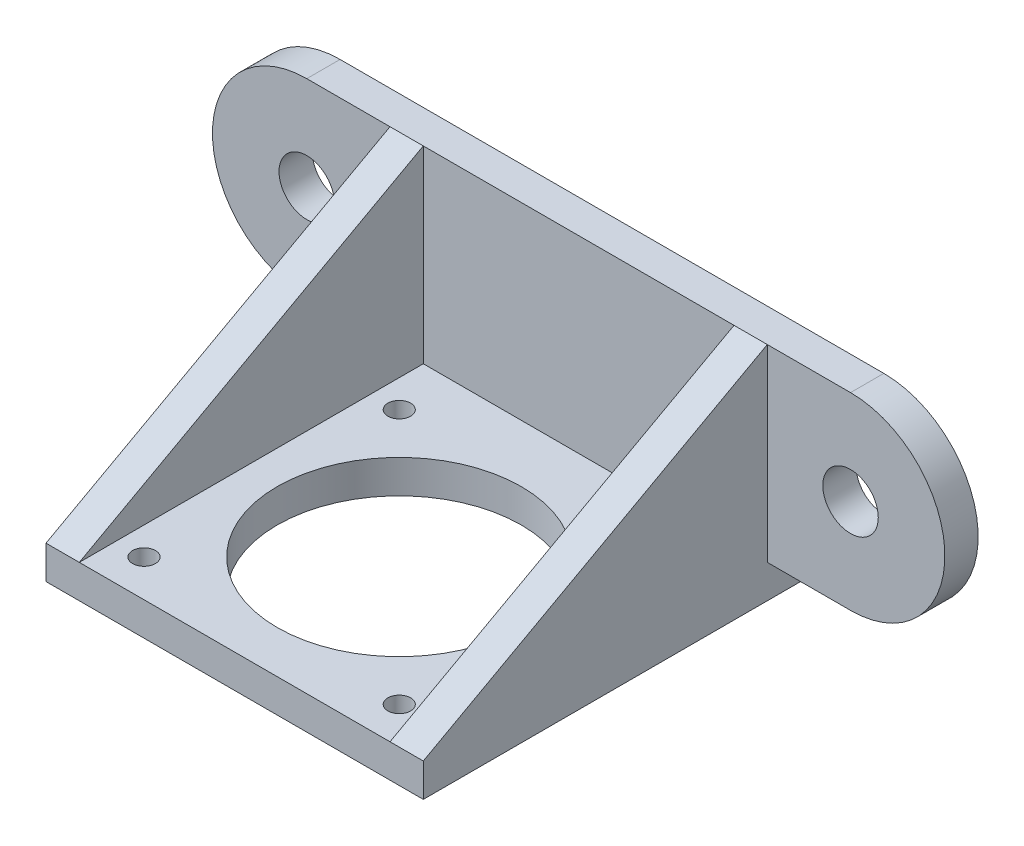
from build123d import *

# Parameters (mm, degrees)
BOSS_EXTRUDE2_DEPTH = 17
RIB2_REACH          = 54.077
SKETCH5_WALL_W      = 141.50907159
SKETCH5_WALL_H      = 3
SKETCH6_R           = 2.5
BOSS_EXTRUDE3_DEPTH = 3
CUT_EXTRUDE1_DEPTH  = 3


with BuildPart() as part:
    # Sketch2 → Boss-Extrude2 (new, symmetric)
    with BuildSketch(Plane(origin=(0, 0, 0), x_dir=(0, 0, -1), z_dir=(1, 0, 0))):
        Polygon((0, 0), (0, 20), (-3, 20), (-3, 3), (-34, 3), (-34, 0), align=None)
    extrude(amount=BOSS_EXTRUDE2_DEPTH, both=True)

    # Sketch5 wall → Rib2 (add, up to next)
    with BuildSketch(Plane(origin=(17, 11.5, 18.5), x_dir=(0, 0.480832611207, -0.876812408671), z_dir=(0, 0.876812408671, 0.480832611207)), mode=Mode.PRIVATE) as rib2_sk1:
        with Locations((0, 1.5)):
            Rectangle(SKETCH5_WALL_W, SKETCH5_WALL_H)
    rib2_tool1 = extrude(rib2_sk1.sketch, amount=-RIB2_REACH, mode=Mode.PRIVATE) - part.part
    rib2 = rib2_tool1.solids().sort_by_distance((17, 11.5, 18.5))[0]
    add(rib2)

    # Sketch6 → Boss-Extrude3 (add)
    with BuildSketch(Plane.XY):
        with BuildLine():
            Line((17, 20), (24.5, 20))
            ThreePointArc((24.5, 20), (33, 11.5), (24.5, 3))
            Line((24.5, 3), (17, 3))
            Line((17, 3), (17, 20))
        make_face()
        with Locations((24.5, 11.5)):
            Circle(SKETCH6_R, mode=Mode.SUBTRACT)
    boss_extrude3 = extrude(amount=BOSS_EXTRUDE3_DEPTH)

    # Mirror1: Rib2, Boss-Extrude3 across plane
    add(rib2.mirror(Plane(origin=(0, 0, 0), x_dir=(0, 0, 1), z_dir=(1, 0, 0))))
    add(boss_extrude3.mirror(Plane(origin=(0, 0, 0), x_dir=(0, 0, 1), z_dir=(1, 0, 0))))

    # Sketch8 → Cut-Extrude1 (cut)
    with BuildSketch(Plane(origin=(0, 3, 0), x_dir=(1, 0, 0), z_dir=(0, 1, 0))):
        with BuildLine():
            ThreePointArc((11, -19.168010742), (0, -8.168010742), (-11, -19.168010742))
            ThreePointArc((-11, -19.168010742), (0, -30.168010742), (11, -19.168010742))
        make_face()
        with BuildLine():
            ThreePointArc((-10.475, -7.668010742), (-11.5, -6.643010742), (-12.525, -7.668010742))
            ThreePointArc((-12.525, -7.668010742), (-11.5, -8.693010742), (-10.475, -7.668010742))
        make_face()
        with BuildLine():
            ThreePointArc((-12.525, -30.668010742), (-11.5, -31.693010742), (-10.475, -30.668010742))
            ThreePointArc((-10.475, -30.668010742), (-11.5, -29.643010742), (-12.525, -30.668010742))
        make_face()
        with BuildLine():
            ThreePointArc((10.475, -7.668010742), (11.5, -8.693010742), (12.525, -7.668010742))
            ThreePointArc((12.525, -7.668010742), (11.5, -6.643010742), (10.475, -7.668010742))
        make_face()
        with BuildLine():
            ThreePointArc((10.475, -30.668010742), (11.5, -31.693010742), (12.525, -30.668010742))
            ThreePointArc((12.525, -30.668010742), (11.5, -29.643010742), (10.475, -30.668010742))
        make_face()
    extrude(amount=-CUT_EXTRUDE1_DEPTH, mode=Mode.SUBTRACT)


solid = part.part
